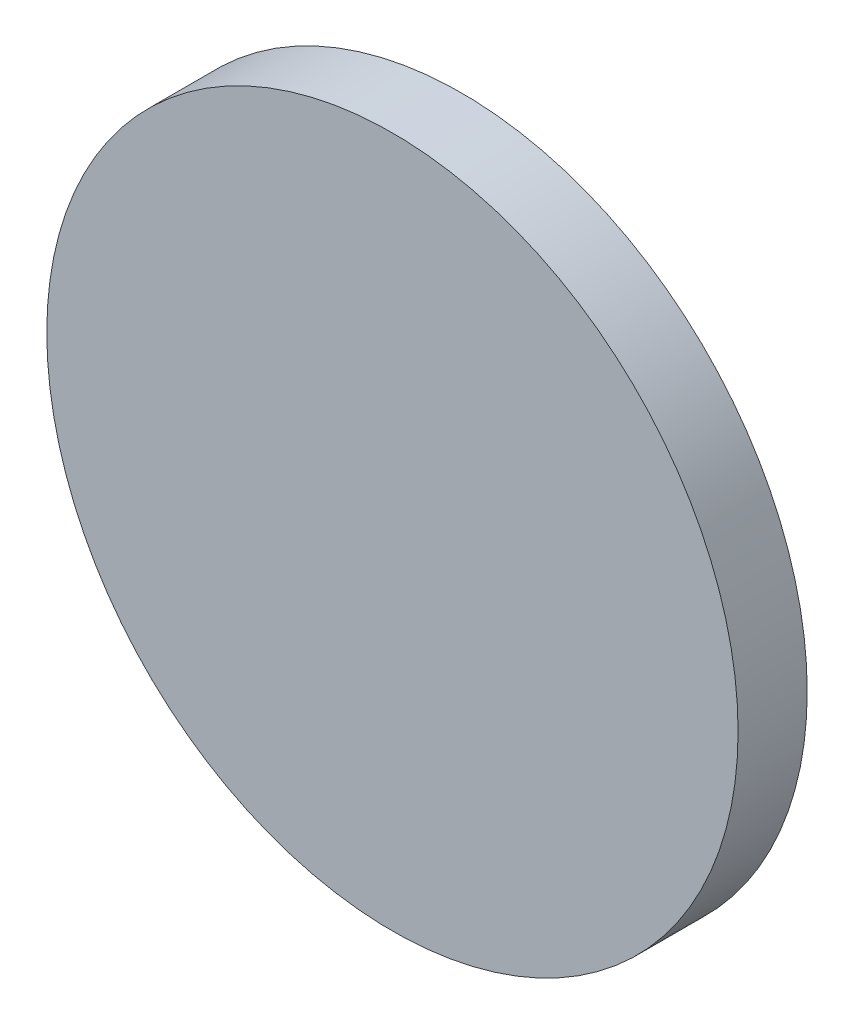
from build123d import *

# Parameters (mm, degrees)
SKETCH3_R           = 31.75
BOSS_EXTRUDE2_DEPTH = 6.35
SKETCH4_R           = 1.143
CUT_EXTRUDE1_DEPTH  = 2.54
CUT_EXTRUDE2_DEPTH  = 2.54


with BuildPart() as part:
    # Sketch3 → Boss-Extrude2 (new body)
    with BuildSketch(Plane.XY):
        Circle(SKETCH3_R)
    extrude(amount=BOSS_EXTRUDE2_DEPTH)

    # Sketch4 → Cut-Extrude1 (cut)
    with BuildSketch(Plane.XY):
        with BuildLine():
            add(Edge.make_bspline(
                [(0.285093718, -13.901273866), (0.141147951, -13.887171676), (0, -13.876527186)],
                knots=[2.110140171, 2.110140171, 2.110140171, 2.153301949, 2.153301949, 2.153301949], degree=2, weights=[1, 0.999767142, 1]))
            add(Edge.make_bspline(
                [(0.285093718, -13.901273866), (1.728006496, -13.880738489), (3.145272016, -13.654183704)],
                knots=[4.729471643, 4.729471643, 4.729471643, 4.90197653, 4.90197653, 4.90197653], degree=2, weights=[1, 0.996282564, 1]))
            add(Edge.make_bspline(
                [(3.145272016, -13.654183704), (4.662818342, -13.411598686), (6.101104758, -12.94103951)],
                knots=[4.90197653, 4.90197653, 4.90197653, 5.086620295, 5.086620295, 5.086620295], degree=2, weights=[1, 0.995741361, 1]))
            add(Edge.make_bspline(
                [(6.101104758, -12.94103951), (8.398568731, -12.189386195), (10.336509093, -10.915933003)],
                knots=[5.086620295, 5.086620295, 5.086620295, 5.380275452, 5.380275452, 5.380275452], degree=2, weights=[1, 0.989240182, 1]))
            add(Edge.make_bspline(
                [(10.336509093, -10.915933003), (13.65255872, -8.736901046), (15.325235714, -5.506199261)],
                knots=[5.380275452, 5.380275452, 5.380275452, 5.875990185, 5.875990185, 5.875990185], degree=2, weights=[1, 0.969440293, 1]))
            add(Edge.make_bspline(
                [(15.325235714, -5.506199261), (16.689879283, -2.870450441), (16.689879283, 0)],
                knots=[5.875990185, 5.875990185, 5.875990185, 6.283185307, 6.283185307, 6.283185307], degree=2, weights=[1, 0.979345512, 1]))
            add(Edge.make_bspline(
                [(16.689879283, 0), (16.689879283, 2.47090436), (15.667871375, 4.790502426)],
                knots=[0, 0, 0, 0.351768553, 0.351768553, 0.351768553], degree=2, weights=[1, 0.984572194, 1]))
            ThreePointArc((15.667871375, 4.790502426), (15.246152328, 5.4662947), (14.938000428, 6.200858896))
            add(Edge.make_bspline(
                [(14.938000428, 6.200858896), (13.261554202, 9.00345036), (10.304720908, 10.936769548)],
                knots=[0.462290104, 0.462290104, 0.462290104, 0.905333422, 0.905333422, 0.905333422], degree=2, weights=[1, 0.975564248, 1]))
            add(Edge.make_bspline(
                [(10.304720908, 10.936769548), (8.379335669, 12.195678609), (6.101104758, 12.94103951)],
                knots=[0.905333422, 0.905333422, 0.905333422, 1.196565012, 1.196565012, 1.196565012], degree=2, weights=[1, 0.989416741, 1]))
            add(Edge.make_bspline(
                [(6.101104758, 12.94103951), (4.662818342, 13.411598686), (3.145272016, 13.654183704)],
                knots=[1.196565012, 1.196565012, 1.196565012, 1.381208778, 1.381208778, 1.381208778], degree=2, weights=[1, 0.995741361, 1]))
            add(Edge.make_bspline(
                [(3.145272016, 13.654183704), (1.847759672, 13.861595531), (0.527233781, 13.896363437)],
                knots=[1.381208778, 1.381208778, 1.381208778, 1.539201041, 1.539201041, 1.539201041], degree=2, weights=[1, 0.996881428, 1]))
            add(Edge.make_bspline(
                [(0, 13.846289536), (0.259050182, 13.865417717), (0.527233781, 13.896363437)],
                knots=[0.983131527, 0.983131527, 0.983131527, 1.062707397, 1.062707397, 1.062707397], degree=2, weights=[1, 0.999208565, 1]))
            add(Edge.make_bspline(
                [(-1.52471534, 13.845163355), (-0.825195404, 13.785357375), (0, 13.846289536)],
                knots=[0.730857997, 0.730857997, 0.730857997, 0.983131527, 0.983131527, 0.983131527], degree=2, weights=[1, 0.9920553, 1]))
            add(Edge.make_bspline(
                [(-1.52471534, 13.845163355), (-4.576425098, 13.611944607), (-7.329613451, 12.490815153)],
                knots=[1.662279564, 1.662279564, 1.662279564, 2.02546554, 2.02546554, 2.02546554], degree=2, weights=[1, 0.983557253, 1]))
            add(Edge.make_bspline(
                [(-7.329613451, 12.490815153), (-9.632246072, 11.553157092), (-11.491033182, 10.083139612)],
                knots=[2.02546554, 2.02546554, 2.02546554, 2.33021929, 2.33021929, 2.33021929], degree=2, weights=[1, 0.988413089, 1]))
            add(Edge.make_bspline(
                [(-11.491033182, 10.083139612), (-16.689879283, 5.971644216), (-16.689879283, 0)],
                knots=[2.33021929, 2.33021929, 2.33021929, 3.141592654, 3.141592654, 3.141592654], degree=2, weights=[1, 0.918831615, 1]))
            add(Edge.make_bspline(
                [(-16.689879283, 0), (-16.689879283, -5.971644216), (-11.491033182, -10.083139612)],
                knots=[3.141592654, 3.141592654, 3.141592654, 3.952966017, 3.952966017, 3.952966017], degree=2, weights=[1, 0.918831615, 1]))
            add(Edge.make_bspline(
                [(-11.491033182, -10.083139612), (-9.771897411, -11.442714154), (-7.666311338, -12.349762421)],
                knots=[3.952966017, 3.952966017, 3.952966017, 4.235138151, 4.235138151, 4.235138151], degree=2, weights=[1, 0.990063859, 1]))
            add(Edge.make_bspline(
                [(-7.666311338, -12.349762421), (-4.68680973, -13.633277639), (-1.343384924, -13.858190888)],
                knots=[4.235138151, 4.235138151, 4.235138151, 4.631810821, 4.631810821, 4.631810821], degree=2, weights=[1, 0.980395741, 1]))
            add(Edge.make_bspline(
                [(0, -13.876527186), (-0.717663487, -13.822405523), (-1.343384924, -13.858190888)],
                knots=[2.153301949, 2.153301949, 2.153301949, 2.371916233, 2.371916233, 2.371916233], degree=2, weights=[1, 0.99403192, 1]))
        make_face()
        with BuildLine():
            add(Edge.make_bspline(
                [(15.132094882, 0), (15.132094882, 8.047610254), (6.101104758, 8.047610254)],
                knots=[0, 0, 0, 1.570796327, 1.570796327, 1.570796327], degree=2, weights=[1, 0.707106781, 1]))
            add(Edge.make_bspline(
                [(6.101104758, -8.047610254), (15.132094882, -8.047610254), (15.132094882, 0)],
                knots=[4.71238898, 4.71238898, 4.71238898, 6.283185307, 6.283185307, 6.283185307], degree=2, weights=[1, 0.707106781, 1]))
            add(Edge.make_bspline(
                [(0, -5.933438019), (2.589256987, -8.047610254), (6.101104758, -8.047610254)],
                knots=[3.970645635, 3.970645635, 3.970645635, 4.71238898, 4.71238898, 4.71238898], degree=2, weights=[1, 0.932011781, 1]))
            add(Edge.make_bspline(
                [(-2.929885365, 0), (-2.929885365, -3.541136939), (0, -5.933438019)],
                knots=[3.141592654, 3.141592654, 3.141592654, 3.970645635, 3.970645635, 3.970645635], degree=2, weights=[1, 0.915307132, 1]))
            add(Edge.make_bspline(
                [(0, 5.933438019), (-2.929885365, 3.541136939), (-2.929885365, 0)],
                knots=[2.312539672, 2.312539672, 2.312539672, 3.141592654, 3.141592654, 3.141592654], degree=2, weights=[1, 0.915307132, 1]))
            add(Edge.make_bspline(
                [(6.101104758, 8.047610254), (2.589256987, 8.047610254), (0, 5.933438019)],
                knots=[1.570796327, 1.570796327, 1.570796327, 2.312539672, 2.312539672, 2.312539672], degree=2, weights=[1, 0.932011781, 1]))
        make_face(mode=Mode.SUBTRACT)
        with Locations((-11.491033182, 5.041569806)):
            Circle(SKETCH4_R, mode=Mode.SUBTRACT)
        with Locations((-11.491033182, -5.041569806)):
            Circle(SKETCH4_R, mode=Mode.SUBTRACT)
        Polygon((-7.46787673, 2.290157982), (-5.177718748, 0), (-7.530812997, -2.353094248), align=None, mode=Mode.SUBTRACT)
        with BuildLine():
            add(Edge.make_bspline(
                [(17.777546671, 3.152891994), (17.010423137, 6.306028067), (14.835880205, 8.937411908)],
                knots=[0.204808238, 0.204808238, 0.204808238, 0.614455544, 0.614455544, 0.614455544], degree=2, weights=[1, 0.979096868, 1]))
            ThreePointArc((17.777546671, 3.152891994), (18.697500427, 2.877644672), (19.653243047, 2.784735873))
            Line((19.653243047, 2.784735873), (19.653243047, 12.709264127))
            ThreePointArc((19.653243047, 12.709264127), (16.594082463, 11.654121932), (14.835880205, 8.937411908))
        make_face()
        with BuildLine():
            ThreePointArc((19.653243047, -2.873311927), (18.682716143, -2.970922849), (17.751064942, -3.259845681))
            add(Edge.make_bspline(
                [(14.906360437, -8.851509355), (16.985395233, -6.299215253), (17.751064942, -3.259845681)],
                knots=[5.675495318, 5.675495318, 5.675495318, 6.071325458, 6.071325458, 6.071325458], degree=2, weights=[1, 0.980478659, 1]))
            ThreePointArc((14.906360437, -8.851509355), (16.622582941, -11.563796399), (19.653243047, -12.620688073))
            Line((19.653243047, -12.620688073), (19.653243047, -2.873311927))
        make_face()
        with BuildLine():
            Line((10.336509093, -20.059933003), (10.336509093, -19.21927919))
            add(Edge.make_bspline(
                [(10.336509093, -19.21927919), (9.657796894, -16.850269205), (4.703244054, -14.973394659)],
                knots=[0.268390842, 0.268390842, 0.268390842, 1.488606212, 1.488606212, 1.488606212], degree=2, weights=[1, 0.819586324, 1]))
            add(Edge.make_bspline(
                [(3.145272016, -15.268147466), (3.931850515, -15.150026059), (4.703244054, -14.973394659)],
                knots=[4.886493376, 4.886493376, 4.886493376, 4.974408422, 4.974408422, 4.974408422], degree=2, weights=[1, 0.999034024, 1]))
            add(Edge.make_bspline(
                [(0, -15.502513285), (1.584614046, -15.502513285), (3.145272016, -15.268147466)],
                knots=[4.71238898, 4.71238898, 4.71238898, 4.886493376, 4.886493376, 4.886493376], degree=2, weights=[1, 0.99621335, 1]))
            add(Edge.make_bspline(
                [(-4.037000396, -15.114479333), (-2.044082286, -15.502513285), (0, -15.502513285)],
                knots=[4.488176971, 4.488176971, 4.488176971, 4.71238898, 4.71238898, 4.71238898], degree=2, weights=[1, 0.9937227, 1]))
            add(Edge.make_bspline(
                [(-4.037000396, -15.114479333), (-4.796171568, -17.179730474), (0, -19.538864094)],
                knots=[3.132654716, 3.132654716, 3.132654716, 4.3982742, 4.3982742, 4.3982742], degree=2, weights=[1, 0.806368976, 1]))
            add(Edge.make_bspline(
                [(0, -19.538864094), (9.000289167, -23.965912724), (10.336509093, -20.059933003)],
                knots=[4.3982742, 4.3982742, 4.3982742, 6.283185307, 6.283185307, 6.283185307], degree=2, weights=[1, 0.587803247, 1]))
        make_face()
        with BuildLine():
            add(Edge.make_bspline(
                [(4.742421852, 14.964383768), (9.619611108, 16.843311628), (10.304720908, 19.212085025)],
                knots=[1.656183086, 1.656183086, 1.656183086, 2.866729076, 2.866729076, 2.866729076], degree=2, weights=[1, 0.822346798, 1]))
            Line((10.304720908, 19.212085025), (10.304720908, 20.080769548))
            add(Edge.make_bspline(
                [(10.304720908, 20.080769548), (8.943802448, 24.008098033), (0, 19.55518613)],
                knots=[3.141592654, 3.141592654, 3.141592654, 5.025190203, 5.025190203, 5.025190203], degree=2, weights=[1, 0.588334457, 1]))
            add(Edge.make_bspline(
                [(0, 19.55518613), (-4.734610871, 17.197933135), (-4.014176875, 15.118910007)],
                knots=[5.025190203, 5.025190203, 5.025190203, 6.283185307, 6.283185307, 6.283185307], degree=2, weights=[1, 0.808617689, 1]))
            add(Edge.make_bspline(
                [(0, 15.502513285), (-2.032231805, 15.502513285), (-4.014176875, 15.118910007)],
                knots=[1.570796327, 1.570796327, 1.570796327, 1.793719247, 1.793719247, 1.793719247], degree=2, weights=[1, 0.9937946, 1]))
            add(Edge.make_bspline(
                [(3.145272016, 15.268147466), (1.584614046, 15.502513285), (0, 15.502513285)],
                knots=[1.396691931, 1.396691931, 1.396691931, 1.570796327, 1.570796327, 1.570796327], degree=2, weights=[1, 0.99621335, 1]))
            add(Edge.make_bspline(
                [(4.742421852, 14.964383768), (3.951870677, 15.147019609), (3.145272016, 15.268147466)],
                knots=[1.306542245, 1.306542245, 1.306542245, 1.396691931, 1.396691931, 1.396691931], degree=2, weights=[1, 0.998984301, 1]))
        make_face()
    extrude(amount=CUT_EXTRUDE1_DEPTH, mode=Mode.SUBTRACT)

    # Sketch8 → Cut-Extrude2 (cut)
    with BuildSketch(Plane(origin=(0, 0, 0), x_dir=(-1, 0, 0), z_dir=(0, 0, -1))):
        Polygon((27.311745716, 12.470248167), (19.908914064, 12.470248167), (19.79342773, 11.030423199), (19.501522021, 11.030423199), (19.501522021, 14.943755939), (19.79342773, 14.943755939), (19.908914064, 13.541108308), (26.760178601, 13.541108308), (26.52974649, 14.943755939), (26.826994358, 14.943755939), align=None)
        Polygon((27.311745716, 6.024343629), (19.851170897, 6.024343629), (19.851170897, 4.572743087), (19.501522021, 4.572743087), (19.501522021, 8.496340188), (19.79342773, 8.496340188), (19.851170897, 7.08995934), (26.760178601, 7.08995934), (26.52974649, 8.492606971), (26.826994358, 8.492606971), align=None)
        Polygon((21.648376682, -1.564936541), (21.648376682, -2.539373572), (22.429122259, -2.539373572), (22.429122259, -1.564936541), (27.311745716, -1.561997736), (27.311745716, -0.967519793), (22.173042221, 2.927384972), (21.648376682, 2.927384972), (21.648376682, -0.685292338), (19.986436732, -0.645965474), (19.79342773, 0.38693453), (19.501522021, 0.38693453), (19.501522021, -2.539373572), (19.79342773, -2.539373572), (19.986436732, -1.612135671), align=None)
        Polygon((26.473856077, -0.685292338), (22.429122259, -0.685292338), (22.429122259, 2.373344958), align=None, mode=Mode.SUBTRACT)
        with BuildLine():
            Line((19.501522021, -4.407763058), (20.817406707, -4.407763058))
            Line((20.817406707, -4.407763058), (20.817406707, -4.883689933))
            Line((20.817406707, -4.883689933), (19.79342773, -4.984485736))
            Line((19.79342773, -4.984485736), (19.622789725, -5.804250744))
            ThreePointArc((19.622789725, -5.804250744), (21.677232395, -7.560006809), (23.731675065, -5.804250744))
            Line((23.731675065, -5.804250744), (23.822862267, -4.500761557))
            Line((23.822862267, -4.500761557), (27.104447464, -4.500761557))
            Line((27.104447464, -4.500761557), (27.104447464, -8.487046376))
            Line((27.104447464, -8.487046376), (26.23913381, -8.487046376))
            Line((26.23913381, -8.487046376), (26.23913381, -4.795315102))
            Line((26.23913381, -4.795315102), (24.08318639, -4.795315102))
            Line((24.08318639, -4.795315102), (24.08318639, -6.286748469))
            ThreePointArc((24.08318639, -6.286748469), (21.697319937, -8.672614922), (19.311453485, -6.286748469))
            Line((19.311453485, -6.286748469), (19.501522021, -4.407763058))
        make_face()
        Polygon((22.429122259, -14.483731996), (22.429122259, -15.423930636), (21.697319937, -15.423930636), (21.648376682, -15.423930636), (21.648376682, -14.446684297), (19.986436732, -14.446684297), (19.781538754, -15.423930636), (19.501522021, -15.423930636), (19.501522021, -12.479191074), (19.781538754, -12.479191074), (19.986436732, -13.505631594), (21.648376682, -13.571823259), (21.648376682, -9.959788278), (22.173042221, -9.959788278), (27.311745716, -13.847805268), (27.311745716, -14.483731996), align=None)
        Polygon((22.429122259, -13.571823259), (26.473856077, -13.571823259), (22.429122259, -10.511519465), align=None, mode=Mode.SUBTRACT)
    extrude(amount=-CUT_EXTRUDE2_DEPTH, mode=Mode.SUBTRACT)


solid = part.part
